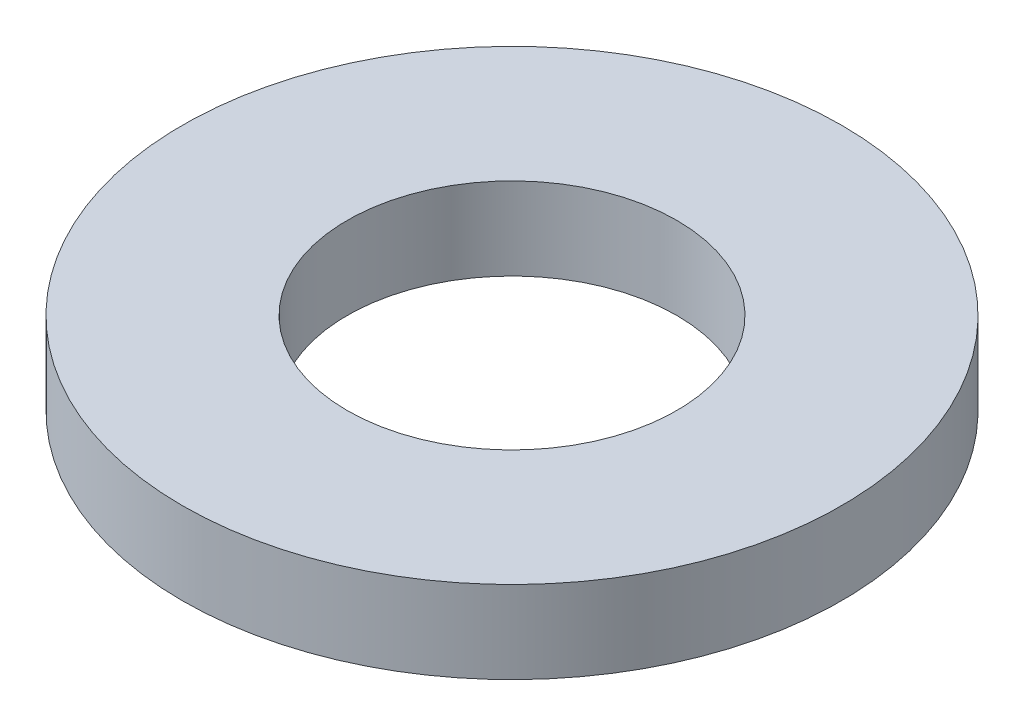
from build123d import *

# Parameters (mm, degrees)
SKETCH1_R           = 6
SKETCH1_R_2         = 3
BOSS_EXTRUDE1_DEPTH = 1.5


with BuildPart() as part:
    # Sketch1 → Boss-Extrude1 (new body)
    with BuildSketch(Plane(origin=(0, 0, 0), x_dir=(1, 0, 0), z_dir=(0, 1, 0))):
        Circle(SKETCH1_R)
        Circle(SKETCH1_R_2, mode=Mode.SUBTRACT)
    extrude(amount=BOSS_EXTRUDE1_DEPTH)


solid = part.part
